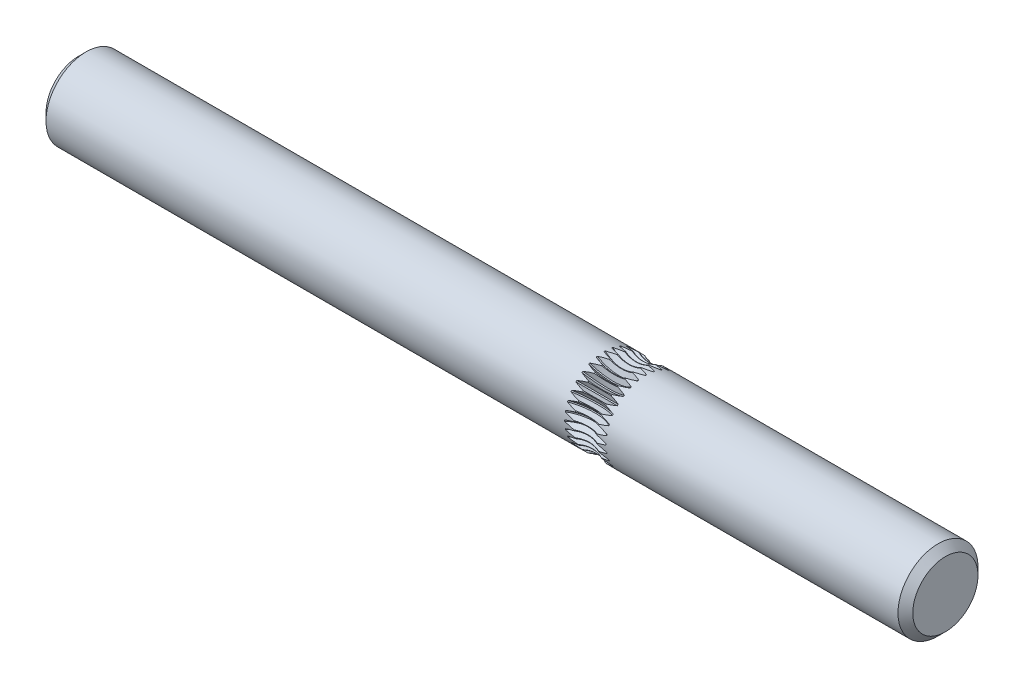
from build123d import *

# Parameters (mm, degrees)
CIRPATTERN1_COUNT = 32
SKETCH10_R        = 2
CHAMFER1_SIZE     = 0.5545


with BuildPart() as part:
    # BodySke → BaseBody (revolve)
    with BuildSketch(Plane.XY):
        Polygon((0, 0), (65, 0), (65, 2.4455), (64.4455, 3), (0, 3), align=None)
    revolve(axis=Axis((0, 0, 0), (1, 0, 0)))

    # Sketch6 → Cut-Revolve1 (revolve, cut)
    with BuildSketch(Plane(origin=(41, 0, 0), x_dir=(0, 0, -1), z_dir=(1, 0, 0))):
        Polygon((-0.04375, 2.421), (0.04375, 2.421), (0.262565752, 2.8), (0.496695277, 2.8), (0.496695277, 3.082884987), (-0.622387477, 3.082884987), (-0.622387477, 2.8), (-0.262565752, 2.8), align=None)
    cut_revolve1 = revolve(axis=Axis((41, 4.8, 2.903425748), (0, 0, -1)), mode=Mode.SUBTRACT)

    # CirPattern1: Cut-Revolve1 ×32 about axis
    cirpattern1_axis = Axis((80.9, 0, 0), (-1, 0, 0))
    for i in range(1, CIRPATTERN1_COUNT):
        add(cut_revolve1.rotate(cirpattern1_axis, i * 360 / CIRPATTERN1_COUNT), mode=Mode.SUBTRACT)

    # Sketch10 → Cut-Revolve2 (revolve, cut)
    with BuildSketch(Plane.XY):
        with Locations((41, 4.8)):
            Circle(SKETCH10_R)
    revolve(axis=Axis((80.9, 0, 0), (-1, 0, 0)), mode=Mode.SUBTRACT)

    # Chamfer1
    chamfer1_edges = [part.edges().sort_by_distance(p)[0] for p in [
        (0, -3, 0),
    ]]
    chamfer(chamfer1_edges, length=CHAMFER1_SIZE)


solid = part.part
